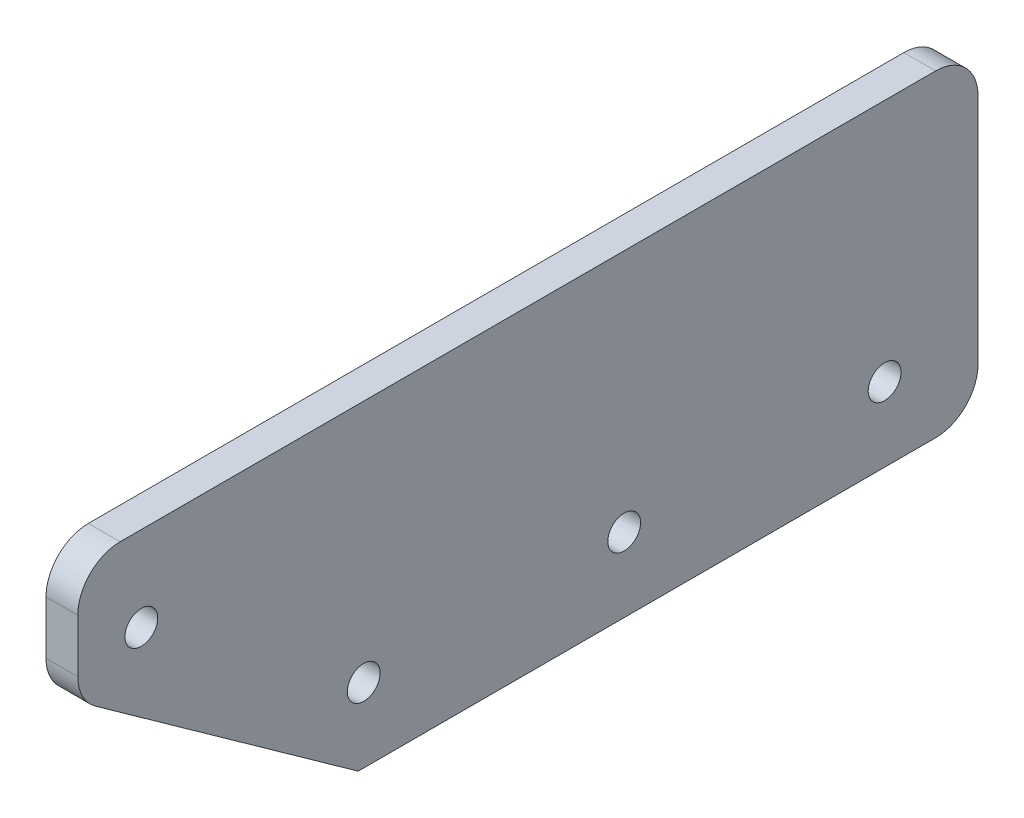
from build123d import *

# Parameters (mm, degrees)
SKIZZE1_W                       = 85
SKIZZE1_H                       = 30
AUFSATZ_LINEAR_AUSTRAGEN1_DEPTH = 3
SKIZZE2_R                       = 1.55
SCHNITT_LINEAR_AUSTRAGEN1_DEPTH = 4
SCHNITT_LINEAR_AUSTRAGEN2_DEPTH = 4
VERRUNDUNG1_R                   = 4


with BuildPart() as part:
    # Skizze1 → Aufsatz-Linear austragen1 (new body)
    with BuildSketch(Plane(origin=(0, 0, 0), x_dir=(0, 0, -1), z_dir=(1, 0, 0))):
        with Locations((42.5, 15)):
            Rectangle(SKIZZE1_W, SKIZZE1_H)
    extrude(amount=AUFSATZ_LINEAR_AUSTRAGEN1_DEPTH)

    # Skizze2 → Schnitt-Linear austragen1 (cut, through all)
    with BuildSketch(Plane(origin=(3, 0, 0), x_dir=(0, 0, -1), z_dir=(1, 0, 0))):
        with Locations((6, 22)):
            Circle(SKIZZE2_R)
        with Locations((27, 7)):
            Circle(SKIZZE2_R)
        with Locations((51.59187467, 7)):
            Circle(SKIZZE2_R)
        with Locations((76.183749339, 7)):
            Circle(SKIZZE2_R)
    extrude(amount=-SCHNITT_LINEAR_AUSTRAGEN1_DEPTH, mode=Mode.SUBTRACT)

    # Skizze3 → Schnitt-Linear austragen2 (cut, through all)
    with BuildSketch(Plane(origin=(3, 0, 0), x_dir=(0, 0, -1), z_dir=(1, 0, 0))):
        Polygon((0, 18.912292628), (26.47720968, 0), (0, 0), align=None)
    extrude(amount=-SCHNITT_LINEAR_AUSTRAGEN2_DEPTH, mode=Mode.SUBTRACT)

    # Verrundung1
    verrundung1_edges = [part.edges().sort_by_distance(p)[0] for p in [
        (1.5, 18.912292628, 0),
        (1.5, 30, 0),
        (1.5, 30, -85),
        (1.5, 0, -85),
    ]]
    fillet(verrundung1_edges, radius=VERRUNDUNG1_R)


solid = part.part
